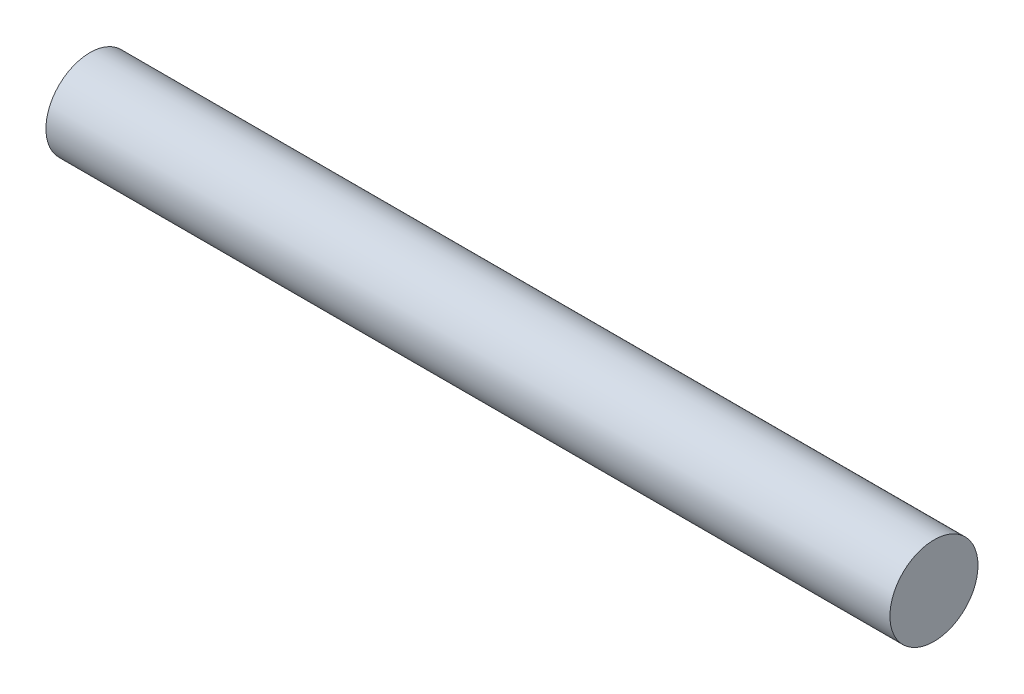
from build123d import *

# Parameters (mm, degrees)
SKETCH1_R           = 1.2
BOSS_EXTRUDE1_DEPTH = 23


with BuildPart() as part:
    # Sketch1 → Boss-Extrude1 (new body)
    with BuildSketch(Plane(origin=(0, 0, 0), x_dir=(0, 0, -1), z_dir=(1, 0, 0))):
        Circle(SKETCH1_R)
    extrude(amount=BOSS_EXTRUDE1_DEPTH)


solid = part.part
